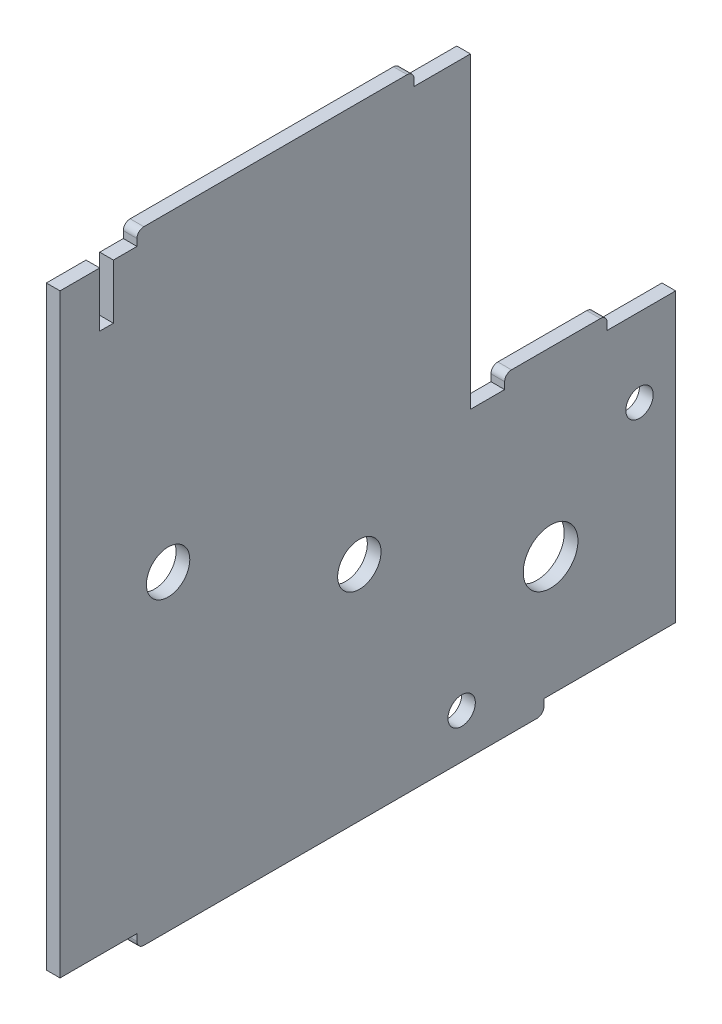
from build123d import *

# Parameters (mm, degrees)
SKETCH1_R           = 4
SKETCH1_R_2         = 2
SKETCH1_R_3         = 3.17
BOSS_EXTRUDE1_DEPTH = 2


with BuildPart() as part:
    # Sketch1 → Boss-Extrude1 (new body)
    with BuildSketch(Plane(origin=(0, 0, 0), x_dir=(0, 0, -1), z_dir=(1, 0, 0))):
        with BuildLine():
            Line((54.519367594, -39.969907591), (54.519367594, 2.030092409))
            Line((54.519367594, 2.030092409), (44.519367594, 2.030092409))
            Line((44.519367594, 2.030092409), (44.519367594, 3.030092409))
            ThreePointArc((44.519367594, 3.030092409), (44.226474376, 3.73719919), (43.519367594, 4.030092409))
            Line((43.519367594, 4.030092409), (30.519367594, 4.030092409))
            ThreePointArc((30.519367594, 4.030092409), (29.812260813, 3.73719919), (29.519367594, 3.030092409))
            Line((29.519367594, 3.030092409), (29.519367594, 2.030092409))
            Line((29.519367594, 2.030092409), (24.519367594, 2.030092409))
            Line((24.519367594, 2.030092409), (24.519367594, 47.030092409))
            Line((24.519367594, 47.030092409), (16.268858723, 47.030092409))
            Line((16.268858723, 47.030092409), (16.268858723, 48.030092409))
            ThreePointArc((16.268858723, 48.030092409), (15.975965504, 48.73719919), (15.268858723, 49.030092409))
            Line((15.268858723, 49.030092409), (-23.230123534, 49.030092409))
            ThreePointArc((-23.230123534, 49.030092409), (-23.937230315, 48.73719919), (-24.230123534, 48.030092409))
            Line((-24.230123534, 48.030092409), (-24.230123534, 47.030092409))
            Line((-24.230123534, 47.030092409), (-27.680632406, 47.030092409))
            Line((-27.680632406, 47.030092409), (-27.680632406, 39.030092409))
            Line((-27.680632406, 39.030092409), (-29.680632406, 39.030092409))
            Line((-29.680632406, 39.030092409), (-29.680632406, 47.030092409))
            Line((-29.680632406, 47.030092409), (-35.480632406, 47.030092409))
            Line((-35.480632406, 47.030092409), (-35.480632406, -39.969907591))
            Line((-35.480632406, -39.969907591), (-24.230123534, -39.969907591))
            Line((-24.230123534, -39.969907591), (-24.230123534, -40.969907591))
            ThreePointArc((-24.230123534, -40.969907591), (-23.937230315, -41.677014372), (-23.230123534, -41.969907591))
            Line((-23.230123534, -41.969907591), (34.268858723, -41.969907591))
            ThreePointArc((34.268858723, -41.969907591), (34.975965504, -41.677014372), (35.268858723, -40.969907591))
            Line((35.268858723, -40.969907591), (35.268858723, -39.969907591))
            Line((35.268858723, -39.969907591), (54.519367594, -39.969907591))
        make_face()
        with Locations((36.233846968, -22.469907591)):
            Circle(SKETCH1_R, mode=Mode.SUBTRACT)
        with Locations((49.233846968, -9.469907591)):
            Circle(SKETCH1_R_2, mode=Mode.SUBTRACT)
        with Locations((23.233846968, -35.469907591)):
            Circle(SKETCH1_R_2, mode=Mode.SUBTRACT)
        with Locations((-19.680632406, 3.530092409)):
            Circle(SKETCH1_R_3, mode=Mode.SUBTRACT)
        with Locations((8.276607281, -9.469907591)):
            Circle(SKETCH1_R_3, mode=Mode.SUBTRACT)
    extrude(amount=BOSS_EXTRUDE1_DEPTH)


solid = part.part
